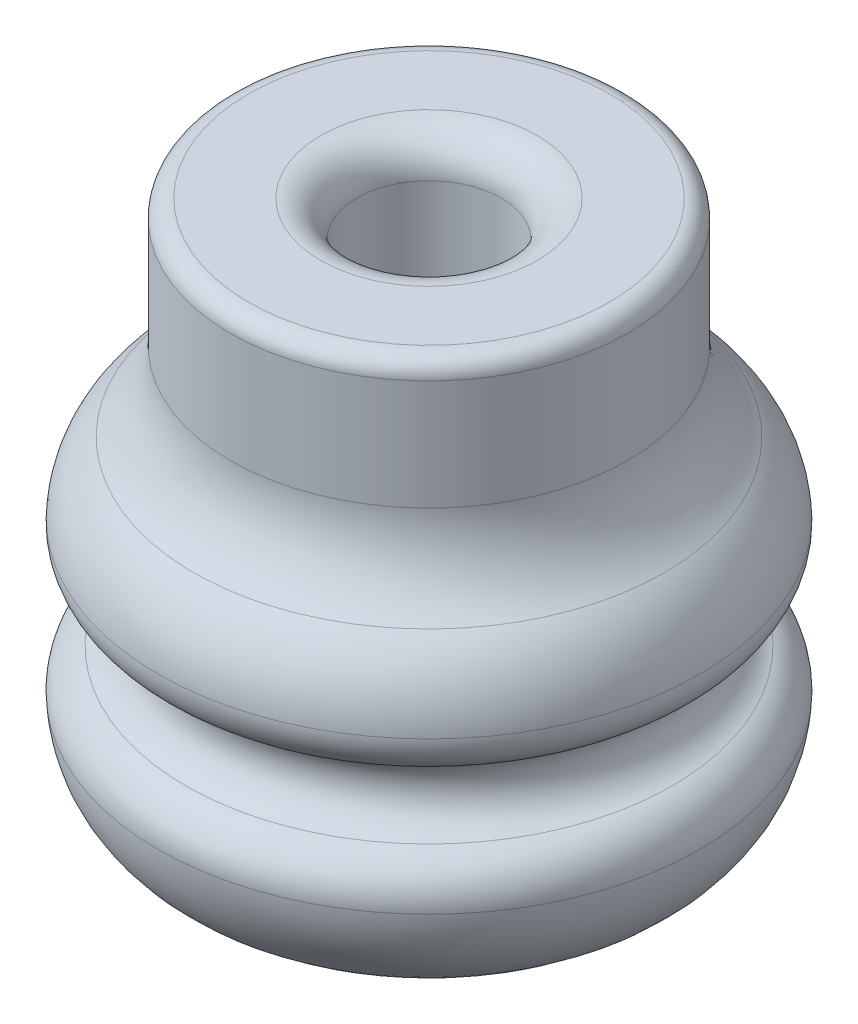
from build123d import *

# Parameters (mm, degrees)
SKETCH3_R          = 4
CUT_EXTRUDE2_DEPTH = 29
FILLET2_R          = 2


with BuildPart() as part:
    # Sketch1 → Revolve1 (revolve)
    with BuildSketch(Plane.XY):
        with BuildLine():
            Line((0, 30), (0, 0))
            Line((0, 0), (-8.405459538, 0))
            ThreePointArc((-8.405459538, 0), (-12.943341762, 1.805707833), (-15, 6.235506106))
            ThreePointArc((-15, 6.235506106), (-14.620310768, 7.635514631), (-13.478274488, 8.529908793))
            ThreePointArc((-13.478274488, 8.529908793), (-12.131882597, 10.441611915), (-13.478274488, 12.353315036))
            ThreePointArc((-13.478274488, 12.353315036), (-14.620310768, 13.247709198), (-15, 14.647717723))
            ThreePointArc((-15, 14.647717723), (-14.425582197, 16.797917102), (-13.041344057, 18.540672952))
            ThreePointArc((-13.041344057, 18.540672952), (-11.535636992, 20.491785587), (-11, 22.897422154))
            Line((-11, 22.897422154), (-11, 29))
            ThreePointArc((-11, 29), (-10.707106781, 29.707106781), (-10, 30))
            Line((-10, 30), (0, 30))
        make_face()
    revolve(axis=Axis((0, 30, 0), (0, -1, 0)))

    # Sketch3 → Cut-Extrude2 (cut)
    with BuildSketch(Plane(origin=(0, 30, 0), x_dir=(1, 0, 0), z_dir=(0, 1, 0))):
        Circle(SKETCH3_R)
    extrude(amount=-CUT_EXTRUDE2_DEPTH, mode=Mode.SUBTRACT)

    # Fillet2
    fillet2_edges = [part.edges().sort_by_distance(p)[0] for p in [
        (-4, 30, 0),
    ]]
    fillet(fillet2_edges, radius=FILLET2_R)


solid = part.part
